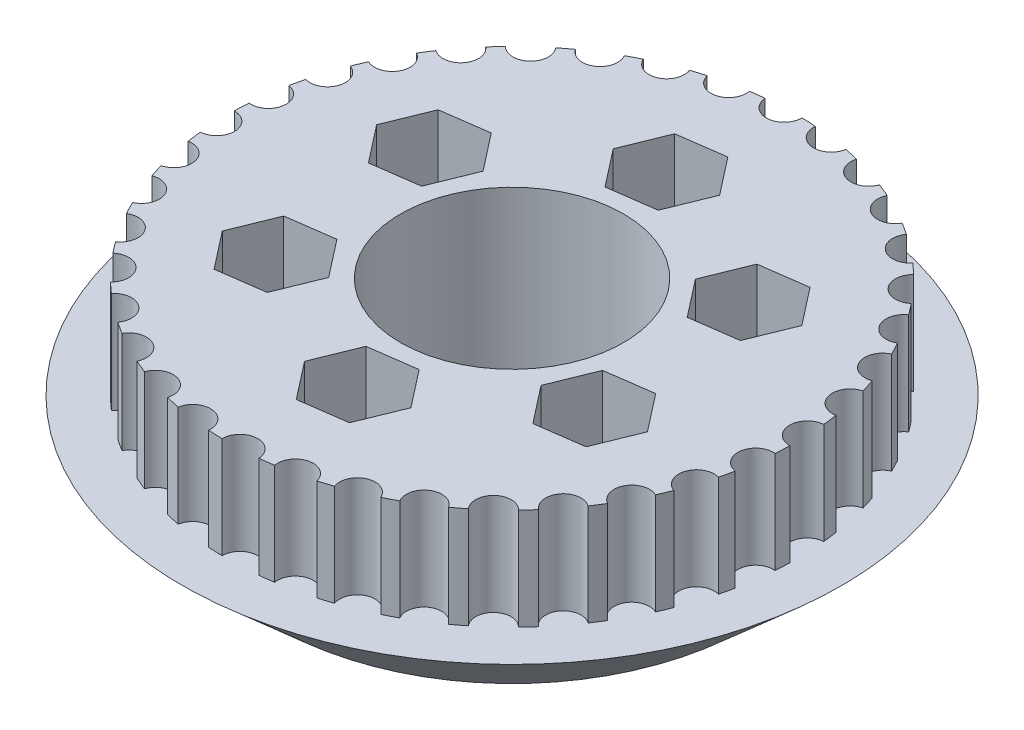
from build123d import *
from build123d.topology import SkipClean

# Parameters (mm, degrees)
SKETCH1_R               = 11
BOSS_EXTRUDE1_DEPTH     = 10
SKETCH2_R               = 32.5
SKETCH3_R               = 23.5
CUT_EXTRUDE1_DEPTH      = 50.360915844
CUT_EXTRUDE1_DEPTH_BACK = 50.360915844
SKETCH3_4_R             = 11
CUT_EXTRUDE2_DEPTH      = 13
SKETCH1_7_R             = 2.75
CUT_EXTRUDE3_DEPTH      = 48.037219444


with BuildPart() as part:
    # Sketch1 → Boss-Extrude1 (new body)
    with BuildSketch(Plane(origin=(0, 0, 0), x_dir=(1, 0, 0), z_dir=(0, 1, 0))):
        with BuildLine():
            ThreePointArc((27.993478679, -0.604277614), (26.22801827, 1.074037998), (27.850343554, 2.891083518))
            ThreePointArc((27.850343554, 2.891083518), (27.77024444, 3.579598264), (27.673126544, 4.26591928))
            ThreePointArc((27.673126544, 4.26591928), (25.643050997, 5.612168524), (26.925202872, 7.683322869))
            ThreePointArc((26.925202872, 7.683322869), (26.726761313, 8.347468463), (26.511940461, 9.006498375))
            ThreePointArc((26.511940461, 9.006498375), (24.278932596, 9.979776149), (25.181953525, 12.242108342))
            ThreePointArc((25.181953525, 12.242108342), (24.871199067, 12.861705057), (24.545202484, 13.473419575))
            ThreePointArc((24.545202484, 13.473419575), (22.177111114, 14.044153326), (22.673563263, 16.428923548))
            ThreePointArc((22.673563263, 16.428923548), (22.259938023, 16.985145252), (21.832670949, 17.530957739))
            ThreePointArc((21.832670949, 17.530957739), (19.401449332, 17.681806011), (19.476248255, 20.116554226))
            ThreePointArc((19.476248255, 20.116554226), (18.972320026, 20.592500403), (18.456764755, 21.055826623))
            ThreePointArc((18.456764755, 21.055826623), (16.036284331, 20.782205967), (15.687157298, 23.192953583))
            ThreePointArc((15.687157298, 23.192953583), (15.108237686, 23.574162849), (14.520059104, 23.940924869))
            ThreePointArc((14.520059104, 23.940924869), (12.183864944, 23.251149112), (11.421420006, 25.564646781))
            ThreePointArc((11.421420006, 25.564646781), (10.785099188, 25.839536286), (10.142168805, 26.098590229))
            ThreePointArc((10.142168805, 26.098590229), (7.961244987, 25.013617856), (6.808648646, 27.159571124))
            ThreePointArc((6.808648646, 27.159571124), (6.13426091, 27.319788489), (5.456113839, 27.463263131))
            ThreePointArc((5.456113839, 27.463263131), (3.496726629, 26.01606048), (1.988999942, 27.929265641))
            ThreePointArc((1.988999942, 27.929265641), (1.297036218, 27.969942743), (0.604277614, 27.993478679))
            ThreePointArc((0.604277614, 27.993478679), (-1.074037998, 26.22801827), (-2.891083518, 27.850343554))
            ThreePointArc((-2.891083518, 27.850343554), (-3.579598264, 27.77024444), (-4.26591928, 27.673126544))
            ThreePointArc((-4.26591928, 27.673126544), (-5.612168524, 25.643050997), (-7.683322869, 26.925202872))
            ThreePointArc((-7.683322869, 26.925202872), (-8.347468463, 26.726761313), (-9.006498375, 26.511940461))
            ThreePointArc((-9.006498375, 26.511940461), (-9.979776149, 24.278932596), (-12.242108342, 25.181953525))
            ThreePointArc((-12.242108342, 25.181953525), (-12.861705057, 24.871199067), (-13.473419575, 24.545202484))
            ThreePointArc((-13.473419575, 24.545202484), (-14.044153326, 22.177111114), (-16.428923548, 22.673563263))
            ThreePointArc((-16.428923548, 22.673563263), (-16.985145252, 22.259938023), (-17.530957739, 21.832670949))
            ThreePointArc((-17.530957739, 21.832670949), (-17.681806011, 19.401449332), (-20.116554226, 19.476248255))
            ThreePointArc((-20.116554226, 19.476248255), (-20.592500403, 18.972320026), (-21.055826623, 18.456764755))
            ThreePointArc((-21.055826623, 18.456764755), (-20.782205967, 16.036284331), (-23.192953583, 15.687157299))
            ThreePointArc((-23.192953583, 15.687157299), (-23.574162849, 15.108237686), (-23.940924869, 14.520059104))
            ThreePointArc((-23.940924869, 14.520059104), (-23.251149112, 12.183864944), (-25.564646781, 11.421420006))
            ThreePointArc((-25.564646781, 11.421420006), (-25.839536286, 10.785099188), (-26.098590229, 10.142168805))
            ThreePointArc((-26.098590229, 10.142168805), (-25.013617856, 7.961244987), (-27.159571124, 6.808648646))
            ThreePointArc((-27.159571124, 6.808648646), (-27.319788489, 6.13426091), (-27.463263131, 5.456113839))
            ThreePointArc((-27.463263131, 5.456113839), (-26.01606048, 3.496726629), (-27.929265641, 1.988999942))
            ThreePointArc((-27.929265641, 1.988999942), (-27.969942743, 1.297036218), (-27.993478679, 0.604277614))
            ThreePointArc((-27.993478679, 0.604277614), (-26.22801827, -1.074037998), (-27.850343554, -2.891083518))
            ThreePointArc((-27.850343554, -2.891083518), (-27.77024444, -3.579598264), (-27.673126544, -4.26591928))
            ThreePointArc((-27.673126544, -4.26591928), (-25.643050997, -5.612168524), (-26.925202872, -7.683322869))
            ThreePointArc((-26.925202872, -7.683322869), (-26.726761313, -8.347468463), (-26.511940461, -9.006498375))
            ThreePointArc((-26.511940461, -9.006498375), (-24.278932596, -9.979776149), (-25.181953525, -12.242108342))
            ThreePointArc((-25.181953525, -12.242108342), (-24.871199067, -12.861705057), (-24.545202484, -13.473419575))
            ThreePointArc((-24.545202484, -13.473419575), (-22.177111114, -14.044153326), (-22.673563263, -16.428923548))
            ThreePointArc((-22.673563263, -16.428923548), (-22.259938023, -16.985145252), (-21.832670949, -17.530957739))
            ThreePointArc((-21.832670949, -17.530957739), (-19.401449332, -17.681806011), (-19.476248255, -20.116554226))
            ThreePointArc((-19.476248255, -20.116554226), (-18.972320026, -20.592500403), (-18.456764755, -21.055826623))
            ThreePointArc((-18.456764755, -21.055826623), (-16.036284331, -20.782205967), (-15.687157298, -23.192953583))
            ThreePointArc((-15.687157298, -23.192953583), (-15.108237686, -23.574162849), (-14.520059104, -23.940924869))
            ThreePointArc((-14.520059104, -23.940924869), (-12.183864944, -23.251149112), (-11.421420006, -25.564646781))
            ThreePointArc((-11.421420006, -25.564646781), (-10.785099188, -25.839536286), (-10.142168805, -26.098590229))
            ThreePointArc((-10.142168805, -26.098590229), (-7.961244987, -25.013617856), (-6.808648646, -27.159571124))
            ThreePointArc((-6.808648646, -27.159571124), (-6.13426091, -27.319788489), (-5.456113839, -27.463263131))
            ThreePointArc((-5.456113839, -27.463263131), (-3.496726629, -26.01606048), (-1.988999942, -27.929265641))
            ThreePointArc((-1.988999942, -27.929265641), (-1.297036218, -27.969942743), (-0.604277614, -27.993478679))
            ThreePointArc((-0.604277614, -27.993478679), (1.074037998, -26.22801827), (2.891083518, -27.850343554))
            ThreePointArc((2.891083518, -27.850343554), (3.579598264, -27.77024444), (4.26591928, -27.673126544))
            ThreePointArc((4.26591928, -27.673126544), (5.612168524, -25.643050997), (7.683322869, -26.925202872))
            ThreePointArc((7.683322869, -26.925202872), (8.347468463, -26.726761312), (9.006498375, -26.511940461))
            ThreePointArc((9.006498375, -26.511940461), (9.979776149, -24.278932596), (12.242108342, -25.181953525))
            ThreePointArc((12.242108342, -25.181953525), (12.861705057, -24.871199067), (13.473419575, -24.545202484))
            ThreePointArc((13.473419575, -24.545202484), (14.044153326, -22.177111114), (16.428923548, -22.673563263))
            ThreePointArc((16.428923548, -22.673563263), (16.985145252, -22.259938023), (17.530957739, -21.832670949))
            ThreePointArc((17.530957739, -21.832670949), (17.681806011, -19.401449332), (20.116554226, -19.476248255))
            ThreePointArc((20.116554226, -19.476248255), (20.592500403, -18.972320026), (21.055826623, -18.456764755))
            ThreePointArc((21.055826623, -18.456764755), (20.782205967, -16.036284331), (23.192953583, -15.687157298))
            ThreePointArc((23.192953583, -15.687157298), (23.574162849, -15.108237686), (23.940924869, -14.520059104))
            ThreePointArc((23.940924869, -14.520059104), (23.251149112, -12.183864944), (25.564646781, -11.421420006))
            ThreePointArc((25.564646781, -11.421420006), (25.839536286, -10.785099188), (26.098590229, -10.142168805))
            ThreePointArc((26.098590229, -10.142168805), (25.013617856, -7.961244987), (27.159571124, -6.808648646))
            ThreePointArc((27.159571124, -6.808648646), (27.319788489, -6.13426091), (27.463263131, -5.456113839))
            ThreePointArc((27.463263131, -5.456113839), (26.01606048, -3.496726629), (27.929265641, -1.988999942))
            ThreePointArc((27.929265641, -1.988999942), (27.969942743, -1.297036218), (27.993478679, -0.604277614))
        make_face()
        Circle(SKETCH1_R, mode=Mode.SUBTRACT)
    extrude(amount=BOSS_EXTRUDE1_DEPTH)

    # Sketch2 → Loft2 section 0
    with BuildSketch(Plane.XZ):
        Circle(SKETCH2_R)
    # Sketch3 → Loft2 section 1
    with BuildSketch(Plane(origin=(0, -8, 0), x_dir=(-1, 0, 0), z_dir=(0, -1, 0))):
        Circle(SKETCH3_R)
    loft()

    # Sketch3_4 → Cut-Extrude1 (cut, two sides: drawn at the far end of the back side and taken through both)
    with SkipClean():  # the faces are left unmerged after this step: merging them gives an invalid solid
        with BuildSketch(Plane(origin=(0, -8, 0), x_dir=(-1, 0, 0), z_dir=(0, -1, 0)).offset(-CUT_EXTRUDE1_DEPTH_BACK)):
            Circle(SKETCH3_4_R)
        extrude(amount=CUT_EXTRUDE1_DEPTH + CUT_EXTRUDE1_DEPTH_BACK, mode=Mode.SUBTRACT)
    add(part.part.scale(1), mode=Mode.REPLACE)  # the faces are merged on a copy

    # Sketch4 → Cut-Extrude2 (cut)
    with BuildSketch(Plane(origin=(0, 10, 0), x_dir=(1, 0, 0), z_dir=(0, 1, 0))):
        Polygon((-10.576848295, 7.715277219), (-13.434334579, 11.383692699), (-18.040018719, 10.743244726), (-19.788216575, 6.434381273), (-16.93073029, 2.765965793), (-12.325046151, 3.406413766), align=None)
        Polygon((-18.323932212, -10.251492132), (-15.466445928, -13.919907613), (-10.860761788, -13.27945964), (-9.112563932, -8.970596187), (-11.970050217, -5.302180706), (-16.575734356, -5.942628679), align=None)
        Polygon((1.393201921, 13.017457925), (3.141399777, 17.326321378), (0.283913493, 20.994736859), (-4.321770647, 20.354288886), (-6.069968503, 16.045425433), (-3.212482218, 12.377009952), align=None)
        Polygon((11.970050217, 5.302180706), (16.575734356, 5.942628679), (18.323932212, 10.251492132), (15.466445928, 13.919907613), (10.860761788, 13.27945964), (9.112563932, 8.970596187), align=None)
        Polygon((10.576848295, -7.715277219), (13.434334579, -11.383692699), (18.040018719, -10.743244726), (19.788216575, -6.434381273), (16.93073029, -2.765965793), (12.325046151, -3.406413766), align=None)
        Polygon((-1.393201921, -13.017457925), (-3.141399777, -17.326321378), (-0.283913493, -20.994736859), (4.321770647, -20.354288886), (6.069968503, -16.045425433), (3.212482218, -12.377009952), align=None)
    extrude(amount=-CUT_EXTRUDE2_DEPTH, mode=Mode.SUBTRACT)

    # Sketch1_7 → Cut-Extrude3 (cut, through all)
    with BuildSketch(Plane(origin=(0, 0, 0), x_dir=(1, 0, 0), z_dir=(0, 1, 0))):
        with Locations((-1.464284363, 16.685873406)):
            Circle(SKETCH1_7_R)
        with Locations((13.718248072, 9.611044159)):
            Circle(SKETCH1_7_R)
        with Locations((15.182532435, -7.074829246)):
            Circle(SKETCH1_7_R)
        with Locations((1.464284363, -16.685873406)):
            Circle(SKETCH1_7_R)
        with Locations((-13.718248072, -9.611044159)):
            Circle(SKETCH1_7_R)
        with Locations((-15.182532435, 7.074829246)):
            Circle(SKETCH1_7_R)
    extrude(amount=-CUT_EXTRUDE3_DEPTH, mode=Mode.SUBTRACT)


solid = part.part
